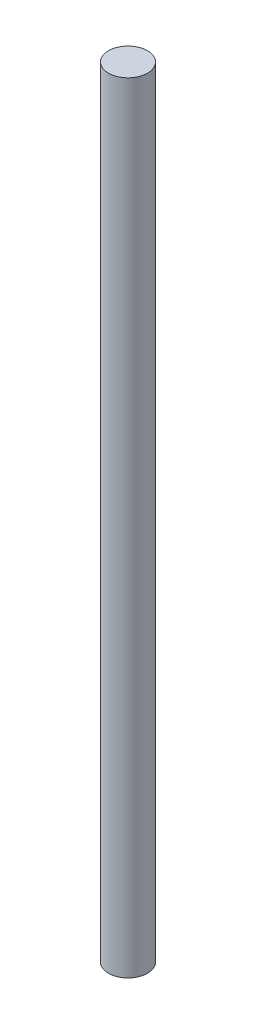
from build123d import *

# Parameters (mm, degrees)
SKETCH1_R           = 1
BOSS_EXTRUDE1_DEPTH = 40


with BuildPart() as part:
    # Sketch1 → Boss-Extrude1 (new body)
    with BuildSketch(Plane(origin=(0, 0, 0), x_dir=(1, 0, 0), z_dir=(0, 1, 0))):
        Circle(SKETCH1_R)
    extrude(amount=BOSS_EXTRUDE1_DEPTH)


solid = part.part
